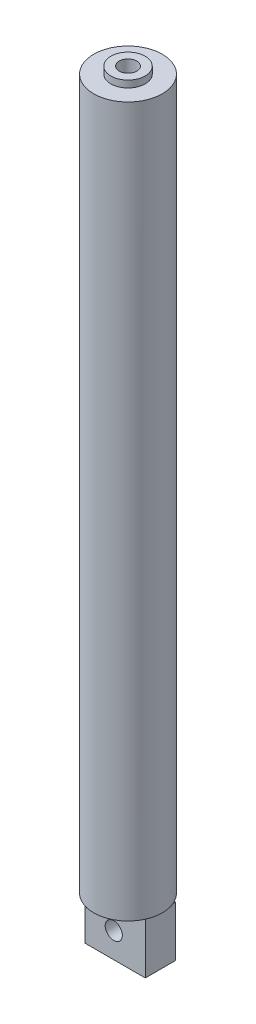
from build123d import *

# Parameters (mm, degrees)
CROQUIS1_R                   = 6.35
SALIENTE_EXTRUIR1_DEPTH      = 127
CROQUIS2_R                   = 3.175
SALIENTE_EXTRUIR2_DEPTH      = 128.27
CROQUIS3_R                   = 1.6256
CORTAR_EXTRUIR1_DEPTH        = 135.128
CORTAR_EXTRUIR1_DEPTH_BACK   = 0.254
CROQUIS4_R                   = 6.35
SALIENTE_EXTRUIR3_DEPTH      = 4.318
CROQUIS5_W                   = 5.579827166
CROQUIS5_H                   = 9.377569363
SALIENTE_EXTRUIR5_DEPTH      = 5.842
SALIENTE_EXTRUIR5_DEPTH_BACK = 5.334
CROQUIS8_R                   = 1.5875
CORTAR_EXTRUIR2_DEPTH        = 23.876
CORTAR_EXTRUIR2_DEPTH_BACK   = 64.262


with BuildPart() as part:
    # Croquis1 → Saliente-Extruir1 (new body)
    with BuildSketch(Plane(origin=(0, 0, 0), x_dir=(1, 0, 0), z_dir=(0, 1, 0))):
        Circle(CROQUIS1_R)
    extrude(amount=SALIENTE_EXTRUIR1_DEPTH)

    # Croquis2 → Saliente-Extruir2 (add)
    with BuildSketch(Plane(origin=(0, 0, 0), x_dir=(1, 0, 0), z_dir=(0, 1, 0))):
        Circle(CROQUIS2_R)
    extrude(amount=SALIENTE_EXTRUIR2_DEPTH)

    # Croquis3 → Cortar-Extruir1 (cut, two sides)
    with BuildSketch(Plane(origin=(0, 0, 0), x_dir=(1, 0, 0), z_dir=(0, 1, 0))) as cortar_extruir1_sk:
        Circle(CROQUIS3_R)
    extrude(amount=CORTAR_EXTRUIR1_DEPTH, mode=Mode.SUBTRACT)
    extrude(cortar_extruir1_sk.sketch, amount=-CORTAR_EXTRUIR1_DEPTH_BACK, mode=Mode.SUBTRACT)

    # Croquis4 → Saliente-Extruir3 (add)
    with BuildSketch(Plane(origin=(0, 0, 0), x_dir=(-1, 0, 0), z_dir=(0, -1, 0))):
        Circle(CROQUIS4_R)
    extrude(amount=SALIENTE_EXTRUIR3_DEPTH)

    # Croquis5 → Saliente-Extruir5 (add, two sides)
    with BuildSketch(Plane(origin=(0, 0, 0), x_dir=(0, 0, -1), z_dir=(1, 0, 0))) as saliente_extruir5_sk:
        with Locations((0.147287334, -9.006784682)):
            Rectangle(CROQUIS5_W, CROQUIS5_H)
    extrude(amount=SALIENTE_EXTRUIR5_DEPTH)
    extrude(saliente_extruir5_sk.sketch, amount=-SALIENTE_EXTRUIR5_DEPTH_BACK)

    # Croquis8 → Cortar-Extruir2 (cut, two sides)
    with BuildSketch(Plane.XY) as cortar_extruir2_sk:
        with Locations((0, -9.006784681)):
            Circle(CROQUIS8_R)
    extrude(amount=CORTAR_EXTRUIR2_DEPTH, mode=Mode.SUBTRACT)
    extrude(cortar_extruir2_sk.sketch, amount=-CORTAR_EXTRUIR2_DEPTH_BACK, mode=Mode.SUBTRACT)


solid = part.part
